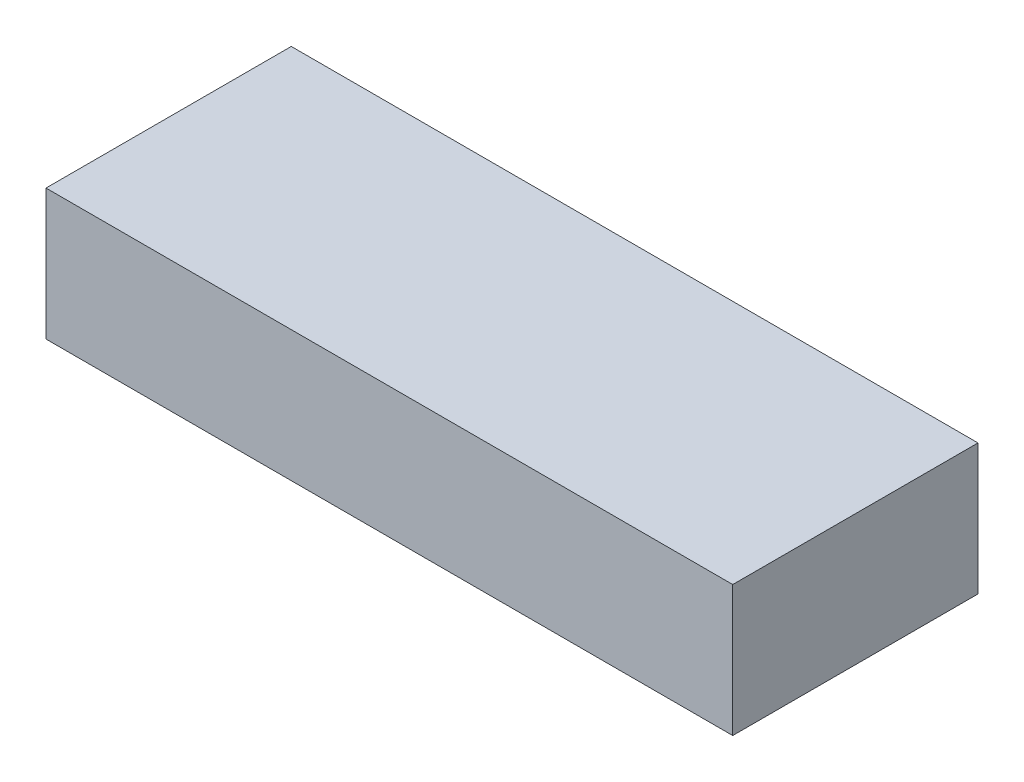
from build123d import *

# Parameters (mm, degrees)
SKETCH1_W           = 133.35
SKETCH1_H           = 47.625
BOSS_EXTRUDE1_DEPTH = 25.4


with BuildPart() as part:
    # Sketch1 → Boss-Extrude1 (new body)
    with BuildSketch(Plane(origin=(0, 0, 0), x_dir=(1, 0, 0), z_dir=(0, 1, 0))):
        Rectangle(SKETCH1_W, SKETCH1_H)
    extrude(amount=BOSS_EXTRUDE1_DEPTH)


solid = part.part
